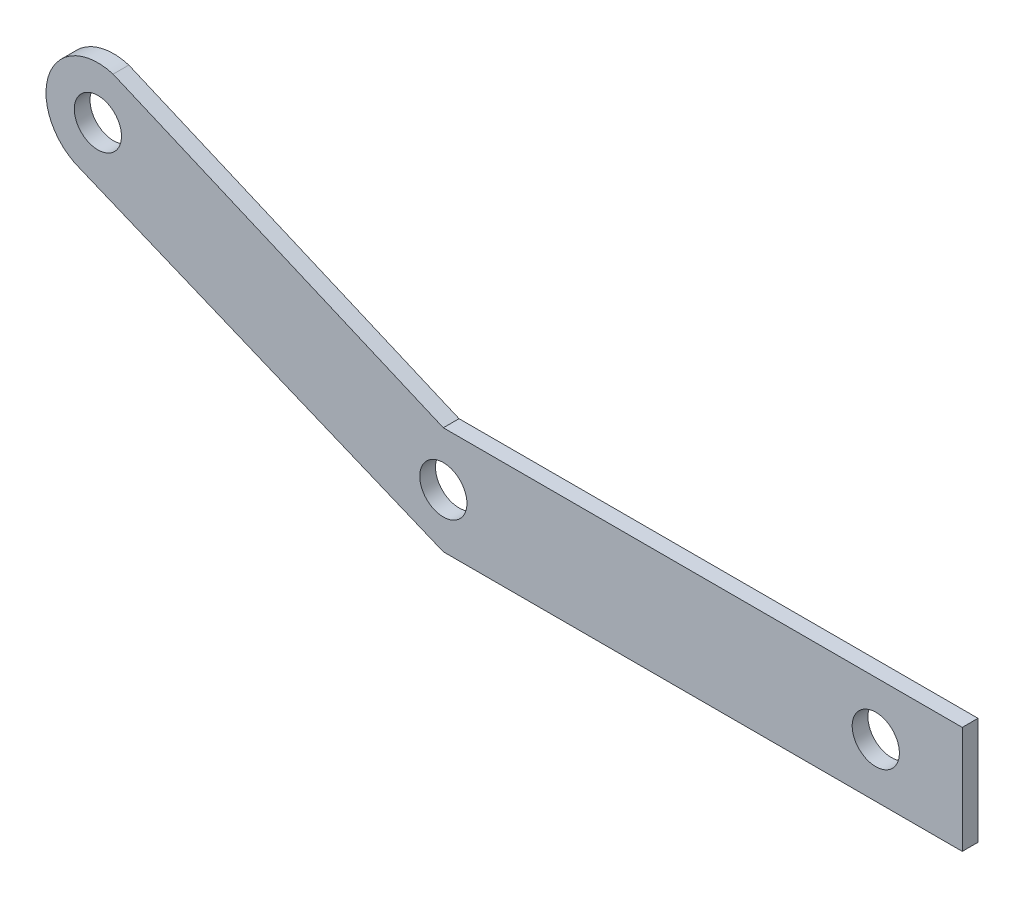
from build123d import *

# Parameters (mm, degrees)
MODEL_R                 = 1.5
SALIENTE_EXTRUIR1_DEPTH = 1


with BuildPart() as part:
    # Model → Saliente-Extruir1 (new body)
    with BuildSketch(Plane.XY):
        with BuildLine():
            Line((36.413729409, 15.560479415), (36.413729409, 8.729479415))
            Line((36.413729409, 8.729479415), (3.413729409, 8.729479415))
            Line((3.413729409, 8.729479415), (-19.719697987, 18.292499154))
            ThreePointArc((-19.719697987, 18.292499154), (-21.676047123, 22.446375255), (-17.587002389, 24.534844015))
            Line((-17.587002389, 24.534844015), (3.413729409, 15.560479415))
            Line((3.413729409, 15.560479415), (36.413729409, 15.560479415))
        make_face()
        with Locations((30.913729409, 12.144979414)):
            Circle(MODEL_R, mode=Mode.SUBTRACT)
        with Locations((3.413729409, 12.144979414)):
            Circle(MODEL_R, mode=Mode.SUBTRACT)
        with Locations((-18.553270591, 21.379479415)):
            Circle(MODEL_R, mode=Mode.SUBTRACT)
    extrude(amount=SALIENTE_EXTRUIR1_DEPTH)


solid = part.part
